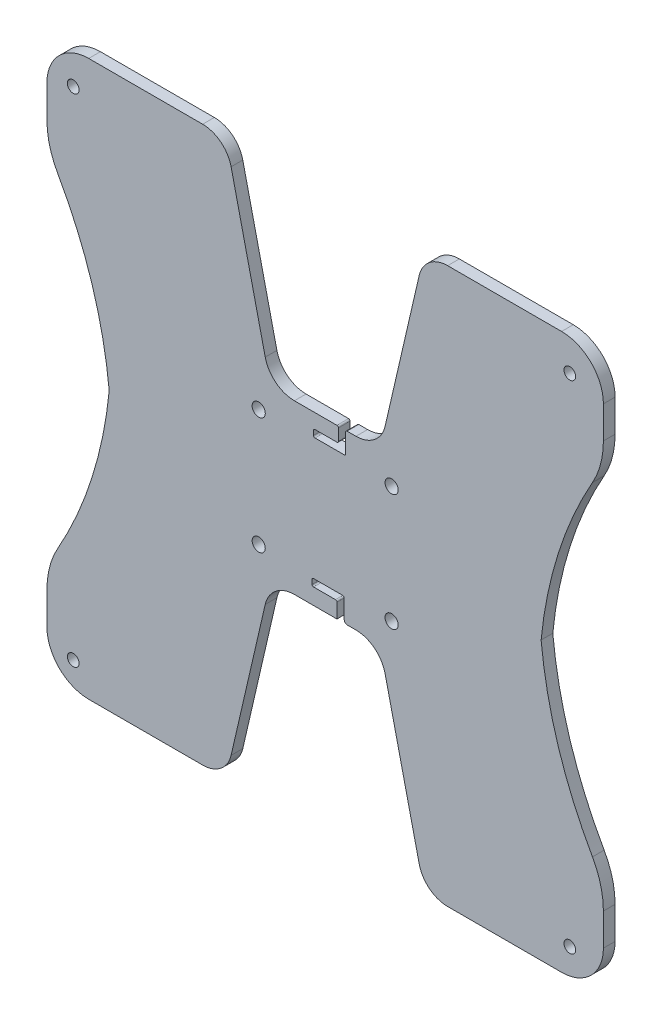
from build123d import *

# Parameters (mm, degrees)
BOSS_EXTRUDE1_DEPTH = 4
SKETCH3_R           = 2
SKETCH3_R_2         = 2.25
CUT_EXTRUDE1_DEPTH  = 4


with BuildPart() as part:
    # Sketch2 → Boss-Extrude1 (new body)
    with BuildSketch(Plane.XY):
        with BuildLine():
            Line((94.375415976, -52.704406223), (94.375415976, -56.704406223))
            ThreePointArc((94.375415976, -56.704406223), (94.228969367, -57.057959614), (93.875415976, -57.204406223))
            Line((93.875415976, -57.204406223), (86.375415976, -57.204406223))
            ThreePointArc((86.375415976, -57.204406223), (86.021862586, -57.350852833), (85.875415976, -57.704406223))
            Line((85.875415976, -57.704406223), (85.875415976, -59.204406223))
            ThreePointArc((85.875415976, -59.204406223), (86.021862586, -59.557959614), (86.375415976, -59.704406223))
            Line((86.375415976, -59.704406223), (96.375415976, -59.704406223))
            ThreePointArc((96.375415976, -59.704406223), (96.728969367, -59.557959614), (96.875415976, -59.204406223))
            Line((96.875415976, -59.204406223), (96.875415976, -52.704406223))
            ThreePointArc((96.875415976, -52.704406223), (97.021862586, -52.350852833), (97.375415976, -52.204406223))
            Line((97.375415976, -52.204406223), (100.375415976, -52.204406223))
            ThreePointArc((100.375415976, -52.204406223), (106.756191002, -49.976139831), (110.36270914, -44.260154531))
            Line((110.36270914, -44.260154531), (122.04253828, 6.330743606))
            ThreePointArc((122.04253828, 6.330743606), (125.561092562, 11.907314631), (131.786238928, 14.081233063))
            Line((131.786238928, 14.081233063), (170.7844924, 14.081233063))
            ThreePointArc((170.7844924, 14.081233063), (180.903868338, 9.889650306), (185.095451094, -0.229725632))
            Line((185.095451094, -0.229725632), (185.095451094, -11.229725632))
            ThreePointArc((185.095451094, -11.229725632), (184.144121557, -18.570812299), (181.352982104, -25.42691337))
            ThreePointArc((181.352982104, -25.42691337), (169.65700257, -52.25234878), (163.771733482, -80.918766937))
            ThreePointArc((163.771733482, -80.918766937), (169.65700257, -109.585185095), (181.352982104, -136.410620505))
            ThreePointArc((181.352982104, -136.410620505), (184.144121557, -143.266721576), (185.095451094, -150.607808243))
            Line((185.095451094, -150.607808243), (185.095451094, -161.607808243))
            ThreePointArc((185.095451094, -161.607808243), (180.903868338, -171.727184181), (170.7844924, -175.918766937))
            Line((170.7844924, -175.918766937), (131.786238928, -175.918766937))
            ThreePointArc((131.786238928, -175.918766937), (125.561092562, -173.744848506), (122.04253828, -168.168277481))
            Line((122.04253828, -168.168277481), (110.36270914, -117.577379344))
            ThreePointArc((110.36270914, -117.577379344), (106.756191002, -111.861394044), (100.375415976, -109.633127651))
            Line((100.375415976, -109.633127651), (97.375415976, -109.633127651))
            ThreePointArc((97.375415976, -109.633127651), (96.668309195, -109.340234433), (96.375415976, -108.633127651))
            Line((96.375415976, -108.633127651), (96.375415976, -102.133127651))
            ThreePointArc((96.375415976, -102.133127651), (96.228969367, -101.779574261), (95.875415976, -101.633127651))
            Line((95.875415976, -101.633127651), (85.875415976, -101.633127651))
            ThreePointArc((85.875415976, -101.633127651), (85.521862586, -101.779574261), (85.375415976, -102.133127651))
            Line((85.375415976, -102.133127651), (85.375415976, -103.633127651))
            ThreePointArc((85.375415976, -103.633127651), (85.521862586, -103.986681042), (85.875415976, -104.133127651))
            Line((85.875415976, -104.133127651), (93.375415976, -104.133127651))
            ThreePointArc((93.375415976, -104.133127651), (93.728969367, -104.279574261), (93.875415976, -104.633127651))
            Line((93.875415976, -104.633127651), (93.875415976, -108.633127651))
            Line((93.875415976, -108.633127651), (93.875415976, -109.633127651))
            Line((93.875415976, -109.633127651), (82.315486211, -109.633127651))
            Line((82.315486211, -109.633127651), (79.315486211, -109.633127651))
            ThreePointArc((79.315486211, -109.633127651), (72.934711186, -111.861394044), (69.328193047, -117.577379344))
            Line((69.328193047, -117.577379344), (57.648363907, -168.168277481))
            ThreePointArc((57.648363907, -168.168277481), (54.129809626, -173.744848506), (47.904663259, -175.918766937))
            Line((47.904663259, -175.918766937), (8.906409788, -175.918766937))
            ThreePointArc((8.906409788, -175.918766937), (-1.21296615, -171.727184181), (-5.404548906, -161.607808243))
            Line((-5.404548906, -161.607808243), (-5.404548906, -150.607808243))
            ThreePointArc((-5.404548906, -150.607808243), (-4.453219369, -143.266721576), (-1.662079916, -136.410620505))
            ThreePointArc((-1.662079916, -136.410620505), (10.033899618, -109.585185095), (15.919168706, -80.918766937))
            ThreePointArc((15.919168706, -80.918766937), (10.033899618, -52.25234878), (-1.662079916, -25.42691337))
            ThreePointArc((-1.662079916, -25.42691337), (-4.453219369, -18.570812299), (-5.404548906, -11.229725632))
            Line((-5.404548906, -11.229725632), (-5.404548906, -0.229725632))
            ThreePointArc((-5.404548906, -0.229725632), (-1.21296615, 9.889650306), (8.906409788, 14.081233063))
            Line((8.906409788, 14.081233063), (47.904663259, 14.081233063))
            ThreePointArc((47.904663259, 14.081233063), (54.129809626, 11.907314631), (57.648363907, 6.330743606))
            Line((57.648363907, 6.330743606), (69.328193047, -44.260154531))
            ThreePointArc((69.328193047, -44.260154531), (72.934711186, -49.976139831), (79.315486211, -52.204406223))
            Line((79.315486211, -52.204406223), (82.315486211, -52.204406223))
            Line((82.315486211, -52.204406223), (93.875415976, -52.204406223))
            ThreePointArc((93.875415976, -52.204406223), (94.228969367, -52.350852833), (94.375415976, -52.704406223))
        make_face()
    extrude(amount=BOSS_EXTRUDE1_DEPTH)

    # Sketch3 → Cut-Extrude1 (cut)
    with BuildSketch(Plane.XY.offset(4)):
        with Locations((3.595451094, 3.081233063)):
            Circle(SKETCH3_R)
        with Locations((3.595451094, -166.918766937)):
            Circle(SKETCH3_R)
        with Locations((67.095451094, -60.918766937)):
            Circle(SKETCH3_R_2)
        with Locations((112.595451094, -60.918766937)):
            Circle(SKETCH3_R_2)
        with Locations((67.095451094, -100.918766947)):
            Circle(SKETCH3_R_2)
        with Locations((112.595451094, -100.918766947)):
            Circle(SKETCH3_R_2)
        with Locations((173.595451094, -166.918766937)):
            Circle(SKETCH3_R)
        with Locations((173.595451094, 3.081233063)):
            Circle(SKETCH3_R)
    extrude(amount=-CUT_EXTRUDE1_DEPTH, mode=Mode.SUBTRACT)


solid = part.part
